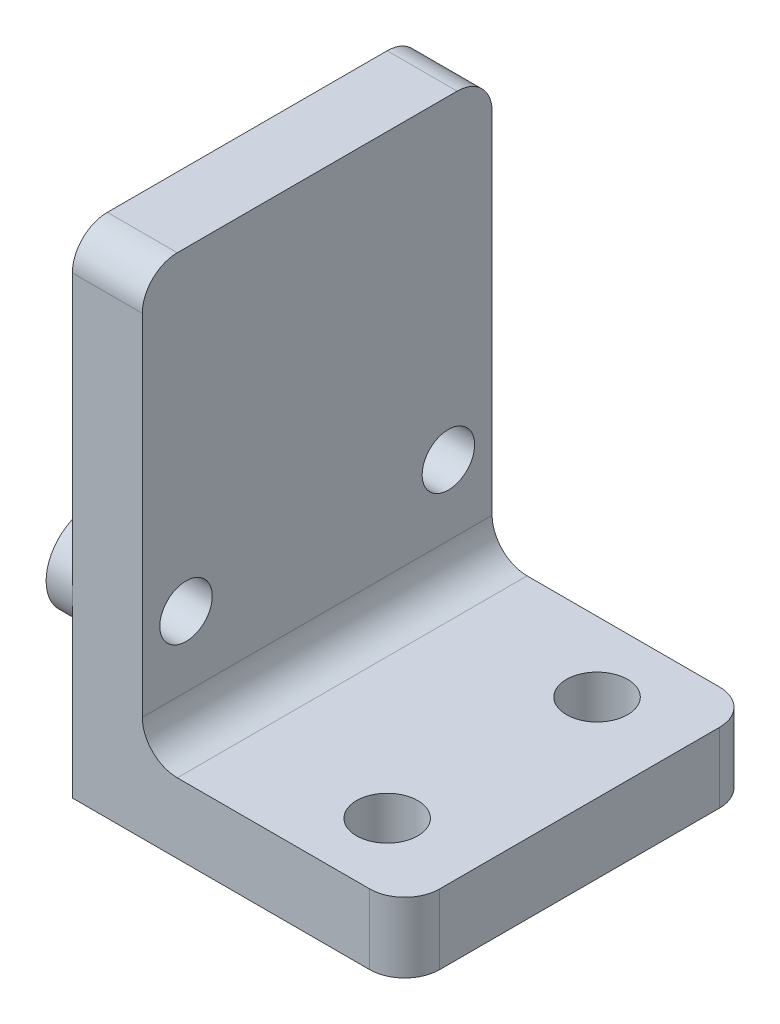
from build123d import *

# Parameters (mm, degrees)
BOSS_EXTRUDE1_DEPTH = 20
SKETCH2_R           = 1.5
CUT_EXTRUDE1_DEPTH  = 20
SKETCH3_R           = 1.75
CUT_EXTRUDE2_DEPTH  = 5
FILLET1_R           = 2
SKETCH4_R           = 2.5
SKETCH4_R_2         = 1.5
BOSS_EXTRUDE2_DEPTH = 1.5


with BuildPart() as part:
    # Sketch1 → Boss-Extrude1 (new body)
    with BuildSketch(Plane.XY):
        Polygon((0, 0), (0, 28), (4, 28), (4, 4), (19, 4), (19, 0), align=None)
    extrude(amount=BOSS_EXTRUDE1_DEPTH)

    # Sketch2 → Cut-Extrude1 (cut, through all)
    with BuildSketch(Plane.ZY):
        with Locations((17.5, 10)):
            Circle(SKETCH2_R)
        with Locations((2.5, 10)):
            Circle(SKETCH2_R)
    extrude(amount=-CUT_EXTRUDE1_DEPTH, mode=Mode.SUBTRACT)

    # Sketch3 → Cut-Extrude2 (cut, through all)
    with BuildSketch(Plane(origin=(0, 4, 0), x_dir=(1, 0, 0), z_dir=(0, 1, 0))):
        with Locations((14, -4)):
            Circle(SKETCH3_R)
        with Locations((14, -16)):
            Circle(SKETCH3_R)
    extrude(amount=-CUT_EXTRUDE2_DEPTH, mode=Mode.SUBTRACT)

    # Fillet1
    fillet1_edges = [part.edges().sort_by_distance(p)[0] for p in [
        (4, 4, 10),
        (2, 28, 20),
        (2, 28, 0),
        (19, 2, 0),
        (19, 2, 20),
    ]]
    fillet(fillet1_edges, radius=FILLET1_R)

    # Sketch4 → Boss-Extrude2 (add)
    with BuildSketch(Plane.ZY):
        with Locations((2.5, 10)):
            Circle(SKETCH4_R)
        with Locations((2.5, 10)):
            Circle(SKETCH4_R_2, mode=Mode.SUBTRACT)
        with Locations((17.5, 10)):
            Circle(SKETCH4_R)
        with Locations((17.5, 10)):
            Circle(SKETCH4_R_2, mode=Mode.SUBTRACT)
    extrude(amount=BOSS_EXTRUDE2_DEPTH)


solid = part.part
